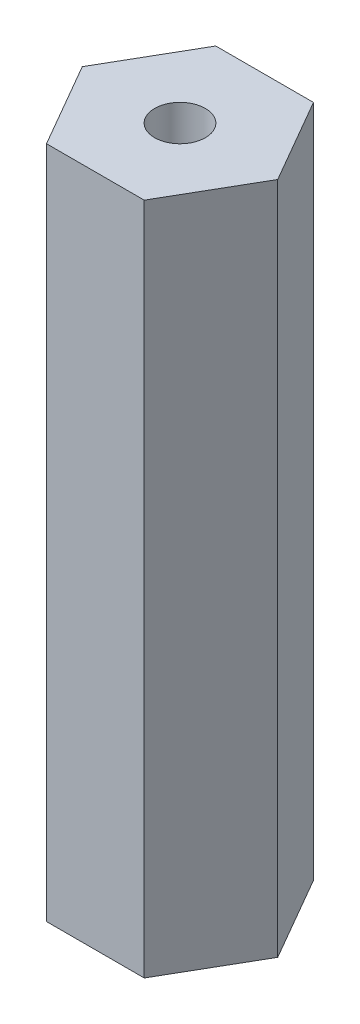
from build123d import *

# Parameters (mm, degrees)
EXTRUDE_START       = 10.8
EXTRUDE_1_DEPTH     = 19.9
SKETCH_2_R          = 0.75
CUT_EXTRUDE_1_DEPTH = 20.9


with BuildPart() as part:
    # Эскиз1 → Бобышка-Вытянуть1 (new body)
    with BuildSketch(Plane(origin=(0, 0, 0), x_dir=(1, 0, 0), z_dir=(0, 1, 0)).offset(EXTRUDE_START)):
        Polygon((2.886751346, 0), (1.443375673, 2.5), (-1.443375673, 2.5), (-2.886751346, 0), (-1.443375673, -2.5), (1.443375673, -2.5), align=None)
    extrude(amount=EXTRUDE_1_DEPTH)

    # Эскиз2 → Вырез-Вытянуть1 (cut, through all)
    with BuildSketch(Plane(origin=(0, 30.7, 0), x_dir=(1, 0, 0), z_dir=(0, 1, 0))):
        Circle(SKETCH_2_R)
    extrude(amount=-CUT_EXTRUDE_1_DEPTH, mode=Mode.SUBTRACT)


solid = part.part
